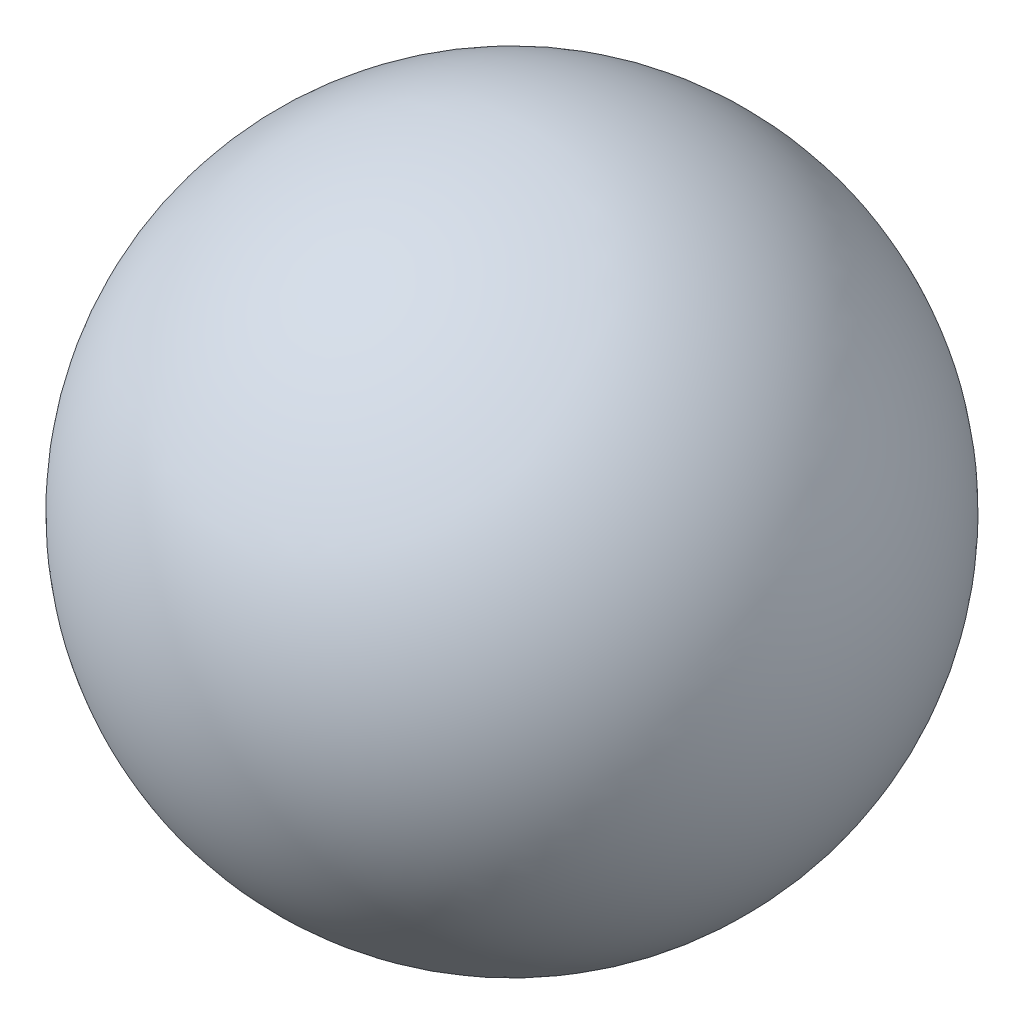
from build123d import *


with BuildPart() as part:
    # 草图1 → 旋转1 (revolve)
    with BuildSketch(Plane(origin=(0, 0, 0), x_dir=(1, 0, 0), z_dir=(0, 1, 0))):
        with BuildLine():
            Line((0, 15), (0, -15))
            ThreePointArc((0, -15), (-15, 0), (0, 15))
        make_face()
    revolve(axis=Axis((0, 0, -15), (0, 0, 1)))


solid = part.part
